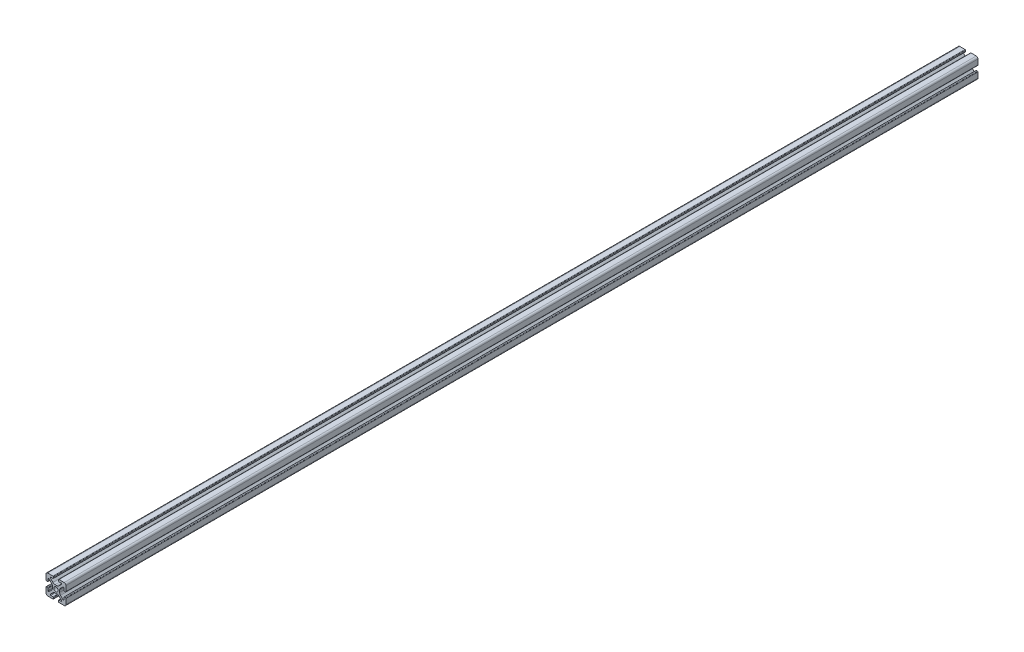
from build123d import *

# Parameters (mm, degrees)
BOSS_EXTRUDE1_DEPTH = 457.2


with BuildPart() as part:
    # Sketch4 → Boss-Extrude1 (new body, symmetric)
    with BuildSketch(Plane.XY):
        with BuildLine():
            Line((3, -10), (8.25, -10))
            ThreePointArc((8.25, -10), (9.487436867, -9.487436867), (10, -8.25))
            Line((10, -8.25), (10, -3))
            ThreePointArc((10, -3), (9.853553391, -2.646446609), (9.5, -2.5))
            Line((9.5, -2.5), (8.424621202, -2.5))
            ThreePointArc((8.424621202, -2.5), (8.071067812, -2.646446609), (7.924621202, -3))
            Line((7.924621202, -3), (7.924621202, -5.25))
            ThreePointArc((7.924621202, -5.25), (7.615962919, -5.711939766), (7.071067812, -5.603553391))
            Line((7.071067812, -5.603553391), (4.478679656, -3.011165235))
            ThreePointArc((4.478679656, -3.011165235), (3.828361402, -2.037895189), (3.6, -0.889844892))
            Line((3.6, -0.889844892), (3.6, 0))
            Line((3.6, 0), (2.15, 0))
            ThreePointArc((2.15, 0), (1.52027958, -1.52027958), (0, -2.15))
            Line((0, -2.15), (0, -3.6))
            Line((0, -3.6), (0.889844892, -3.6))
            ThreePointArc((0.889844892, -3.6), (2.037895189, -3.828361402), (3.011165235, -4.478679656))
            Line((3.011165235, -4.478679656), (5.603553391, -7.071067812))
            ThreePointArc((5.603553391, -7.071067812), (5.711939766, -7.615962919), (5.25, -7.924621202))
            Line((5.25, -7.924621202), (3, -7.924621202))
            ThreePointArc((3, -7.924621202), (2.646446609, -8.071067812), (2.5, -8.424621202))
            Line((2.5, -8.424621202), (2.5, -9.5))
            ThreePointArc((2.5, -9.5), (2.646446609, -9.853553391), (3, -10))
        make_face()
    extrude(amount=BOSS_EXTRUDE1_DEPTH, both=True)

    # Mirror1: part across plane


with BuildPart() as part_1:
    add(part.part)
    add(part.part.mirror(Plane(origin=(0, 0, 0), x_dir=(0, 0, 1), z_dir=(1, 0, 0))))

    # Mirror2: part across plane


with BuildPart() as part_2:
    add(part_1.part)
    add(part_1.part.mirror(Plane.ZX))


solid = part_2.part
